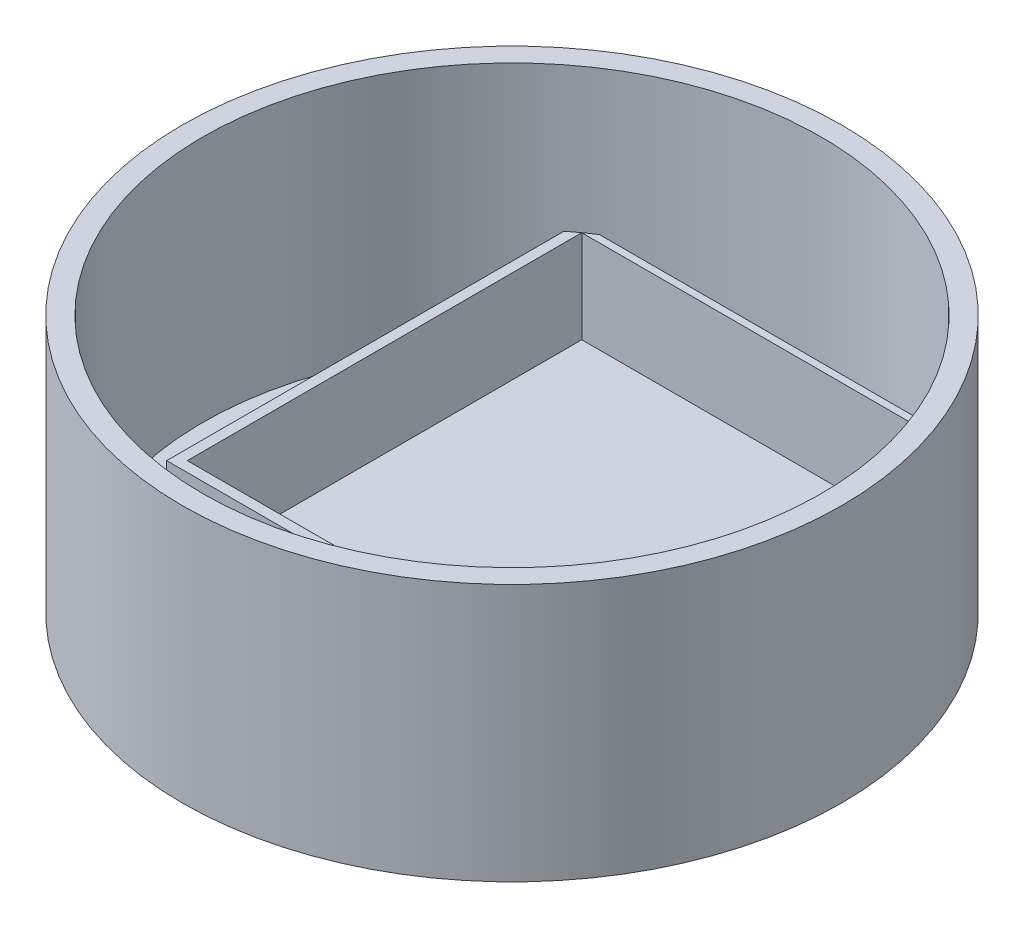
from build123d import *

# Parameters (mm, degrees)
SKETCH2_R           = 32
BOSS_EXTRUDE1_DEPTH = 25
SKETCH3_R           = 30
CUT_EXTRUDE1_DEPTH  = 24
BOSS_EXTRUDE2_DEPTH = 10
CUT_EXTRUDE2_DEPTH  = 9


with BuildPart() as part:
    # Sketch2 → Boss-Extrude1 (new body)
    with BuildSketch(Plane(origin=(0, 0, 0), x_dir=(1, 0, 0), z_dir=(0, 1, 0))):
        Circle(SKETCH2_R)
    extrude(amount=BOSS_EXTRUDE1_DEPTH)

    # Sketch3 → Cut-Extrude1 (cut)
    with BuildSketch(Plane(origin=(0, 25, 0), x_dir=(1, 0, 0), z_dir=(0, 1, 0))):
        Circle(SKETCH3_R)
    extrude(amount=-CUT_EXTRUDE1_DEPTH, mode=Mode.SUBTRACT)

    # Sketch4 → Boss-Extrude2 (add)
    with BuildSketch(Plane(origin=(0, 1, 0), x_dir=(1, 0, 0), z_dir=(0, 1, 0))):
        with BuildLine():
            Line((-18.541196676, -14.972239163), (18.541196676, -14.975032814))
            Line((18.541196676, -14.975032814), (18.541196676, 23.584402172))
            ThreePointArc((18.541196676, 23.584402172), (17.556036053, 24.32664379), (16.541196676, 25.027760837))
            Line((16.541196676, 25.027760837), (-16.541196676, 25.027760837))
            ThreePointArc((-16.541196676, 25.027760837), (-17.556036053, 24.32664379), (-18.541196676, 23.584402172))
            Line((-18.541196676, 23.584402172), (-18.541196676, -14.972239163))
        make_face()
    extrude(amount=BOSS_EXTRUDE2_DEPTH)

    # Sketch5 → Cut-Extrude2 (cut)
    with BuildSketch(Plane(origin=(0, 11, 0), x_dir=(1, 0, 0), z_dir=(0, 1, 0))):
        Polygon((-17.541196676, -13.973635989), (17.541196676, -13.973635989), (17.556036053, 24.32664379), (-17.556036053, 24.32664379), align=None)
    extrude(amount=-CUT_EXTRUDE2_DEPTH, mode=Mode.SUBTRACT)


solid = part.part
